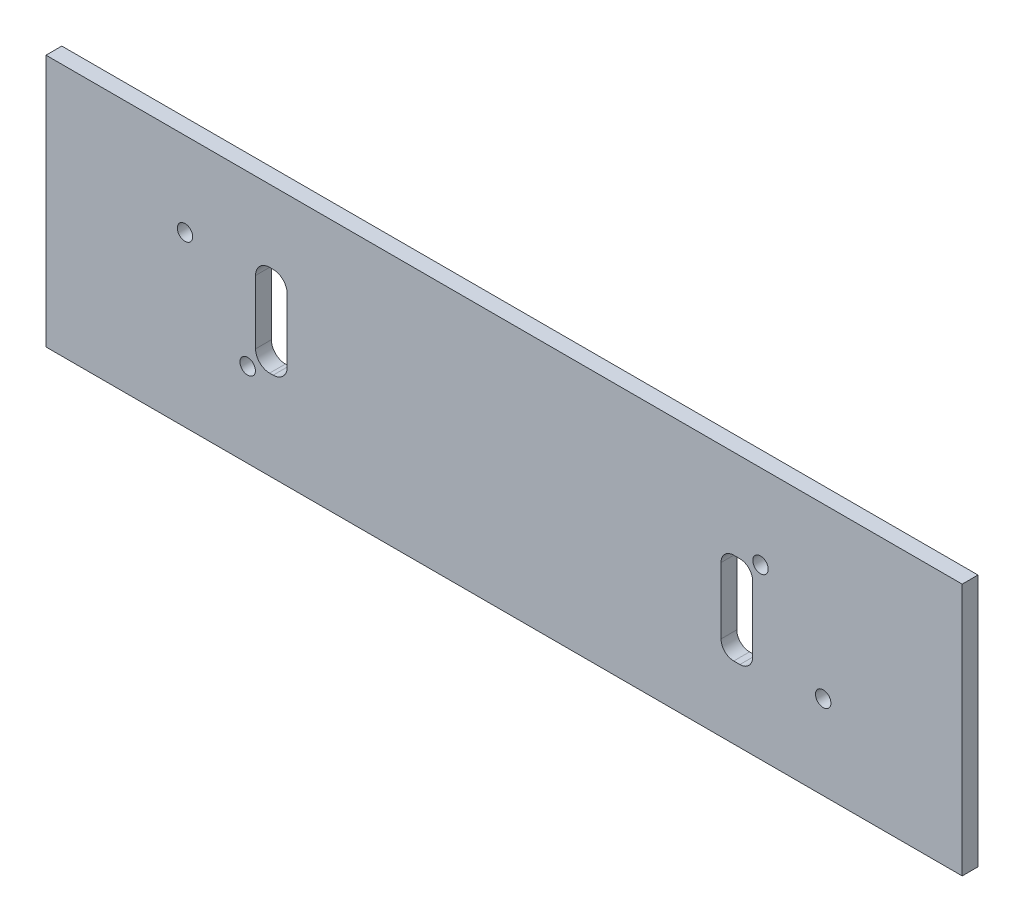
from build123d import *

# Parameters (mm, degrees)
SKETCH2_W           = 184.15
SKETCH2_H           = 50.8
BOSS_EXTRUDE1_DEPTH = 1.5875
SKETCH3_R           = 1.55
CUT_EXTRUDE1_DEPTH  = 5.08


with BuildPart() as part:
    # Sketch2 → Boss-Extrude1 (new body, symmetric)
    with BuildSketch(Plane.XY):
        Rectangle(SKETCH2_W, SKETCH2_H)
    extrude(amount=BOSS_EXTRUDE1_DEPTH, both=True)

    # Sketch3 → Cut-Extrude1 (cut)
    with BuildSketch(Plane(origin=(0, 0, -1.5875), x_dir=(-1, 0, 0), z_dir=(0, 0, -1))):
        with Locations((-51.535, 8.49)):
            Circle(SKETCH3_R)
        with Locations((-64.135, -8.51)):
            Circle(SKETCH3_R)
        with Locations((64.135, 8.51)):
            Circle(SKETCH3_R)
        with Locations((51.535, -8.49)):
            Circle(SKETCH3_R)
        with BuildLine():
            Line((-46.159267508, -10.9375), (-47.390732492, -10.9375))
            ThreePointArc((-47.390732492, -10.9375), (-49.200407902, -10.187907902), (-49.95, -8.378232492))
            Line((-49.95, -8.378232492), (-49.95, 4.918232492))
            ThreePointArc((-49.95, 4.918232492), (-49.200407902, 6.727907902), (-47.390732492, 7.4775))
            Line((-47.390732492, 7.4775), (-46.159267508, 7.4775))
            ThreePointArc((-46.159267508, 7.4775), (-44.349592098, 6.727907902), (-43.6, 4.918232492))
            Line((-43.6, 4.918232492), (-43.6, -8.378232492))
            ThreePointArc((-43.6, -8.378232492), (-44.349592098, -10.187907902), (-46.159267508, -10.9375))
        make_face()
        with BuildLine():
            Line((46.419318463, -7.4775), (47.130681537, -7.4775))
            ThreePointArc((47.130681537, -7.4775), (49.124240741, -6.651740741), (49.95, -4.658181537))
            Line((49.95, -4.658181537), (49.95, 8.118181537))
            ThreePointArc((49.95, 8.118181537), (49.124240741, 10.111740741), (47.130681537, 10.9375))
            Line((47.130681537, 10.9375), (46.419318463, 10.9375))
            ThreePointArc((46.419318463, 10.9375), (44.425759259, 10.111740741), (43.6, 8.118181537))
            Line((43.6, 8.118181537), (43.6, -4.658181537))
            ThreePointArc((43.6, -4.658181537), (44.425759259, -6.651740741), (46.419318463, -7.4775))
        make_face()
    extrude(amount=-CUT_EXTRUDE1_DEPTH, mode=Mode.SUBTRACT)


solid = part.part
